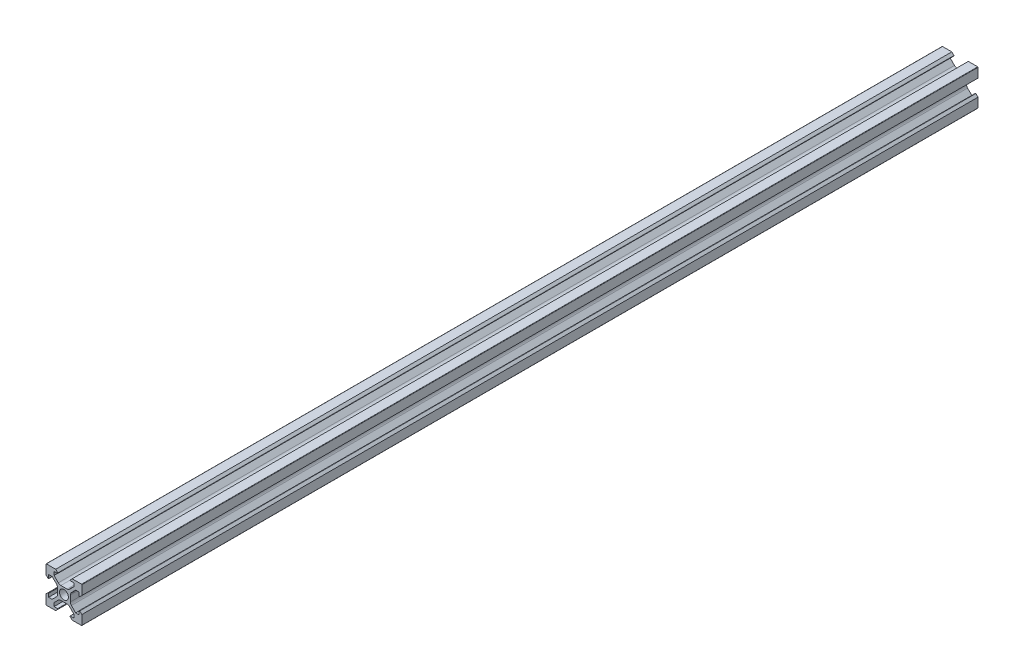
from build123d import *

# Parameters (mm, degrees)
ESBO_O1_R                = 2.5
RESSALTO_EXTRUS_O1_DEPTH = 500


with BuildPart() as part:
    # Esboço1 → Ressalto-extrusão1 (new body)
    with BuildSketch(Plane.XY):
        with BuildLine():
            Line((-4.6, -10), (-9.8, -10))
            ThreePointArc((-9.8, -10), (-9.941421356, -9.941421356), (-10, -9.8))
            Line((-10, -9.8), (-10, -4.6))
            Line((-10, -4.6), (-8.841421356, -3.441421356))
            ThreePointArc((-8.841421356, -3.441421356), (-8.623463314, -3.398066806), (-8.5, -3.582842712))
            Line((-8.5, -3.582842712), (-8.5, -5.5))
            Line((-8.5, -5.5), (-6.560660172, -5.5))
            Line((-6.560660172, -5.5), (-4.185786438, -3.125126266))
            ThreePointArc((-4.185786438, -3.125126266), (-3.752240935, -2.476279568), (-3.6, -1.710912703))
            Line((-3.6, -1.710912703), (-3.6, 1.710912703))
            ThreePointArc((-3.6, 1.710912703), (-3.752240935, 2.476279568), (-4.185786438, 3.125126266))
            Line((-4.185786438, 3.125126266), (-6.560660172, 5.5))
            Line((-6.560660172, 5.5), (-8.5, 5.5))
            Line((-8.5, 5.5), (-8.5, 3.582842712))
            ThreePointArc((-8.5, 3.582842712), (-8.623463314, 3.398066806), (-8.841421356, 3.441421356))
            Line((-8.841421356, 3.441421356), (-10, 4.6))
            Line((-10, 4.6), (-10, 9.8))
            ThreePointArc((-10, 9.8), (-9.941421356, 9.941421356), (-9.8, 10))
            Line((-9.8, 10), (-4.6, 10))
            Line((-4.6, 10), (-3.441421356, 8.841421356))
            ThreePointArc((-3.441421356, 8.841421356), (-3.398066806, 8.623463314), (-3.582842712, 8.5))
            Line((-3.582842712, 8.5), (-5.5, 8.5))
            Line((-5.5, 8.5), (-5.5, 6.560660172))
            Line((-5.5, 6.560660172), (-3.125126266, 4.185786438))
            ThreePointArc((-3.125126266, 4.185786438), (-2.476279568, 3.752240935), (-1.710912703, 3.6))
            Line((-1.710912703, 3.6), (1.710912703, 3.6))
            ThreePointArc((1.710912703, 3.6), (2.476279568, 3.752240935), (3.125126266, 4.185786438))
            Line((3.125126266, 4.185786438), (5.5, 6.560660172))
            Line((5.5, 6.560660172), (5.5, 8.5))
            Line((5.5, 8.5), (3.582842712, 8.5))
            ThreePointArc((3.582842712, 8.5), (3.398066806, 8.623463314), (3.441421356, 8.841421356))
            Line((3.441421356, 8.841421356), (4.6, 10))
            Line((4.6, 10), (9.8, 10))
            ThreePointArc((9.8, 10), (9.941421356, 9.941421356), (10, 9.8))
            Line((10, 9.8), (10, 4.6))
            Line((10, 4.6), (8.841421356, 3.441421356))
            ThreePointArc((8.841421356, 3.441421356), (8.623463314, 3.398066806), (8.5, 3.582842712))
            Line((8.5, 3.582842712), (8.5, 5.5))
            Line((8.5, 5.5), (6.560660172, 5.5))
            Line((6.560660172, 5.5), (4.185786438, 3.125126266))
            ThreePointArc((4.185786438, 3.125126266), (3.752240935, 2.476279568), (3.6, 1.710912703))
            Line((3.6, 1.710912703), (3.6, -1.710912703))
            ThreePointArc((3.6, -1.710912703), (3.752240935, -2.476279568), (4.185786438, -3.125126266))
            Line((4.185786438, -3.125126266), (6.560660172, -5.5))
            Line((6.560660172, -5.5), (8.5, -5.5))
            Line((8.5, -5.5), (8.5, -3.582842712))
            ThreePointArc((8.5, -3.582842712), (8.623463314, -3.398066806), (8.841421356, -3.441421356))
            Line((8.841421356, -3.441421356), (10, -4.6))
            Line((10, -4.6), (10, -9.8))
            ThreePointArc((10, -9.8), (9.941421356, -9.941421356), (9.8, -10))
            Line((9.8, -10), (4.6, -10))
            Line((4.6, -10), (3.441421356, -8.841421356))
            ThreePointArc((3.441421356, -8.841421356), (3.398066806, -8.623463314), (3.582842712, -8.5))
            Line((3.582842712, -8.5), (5.5, -8.5))
            Line((5.5, -8.5), (5.5, -6.560660172))
            Line((5.5, -6.560660172), (3.125126266, -4.185786438))
            ThreePointArc((3.125126266, -4.185786438), (2.476279568, -3.752240935), (1.710912703, -3.6))
            Line((1.710912703, -3.6), (-1.710912703, -3.6))
            ThreePointArc((-1.710912703, -3.6), (-2.476279568, -3.752240935), (-3.125126266, -4.185786438))
            Line((-3.125126266, -4.185786438), (-5.5, -6.560660172))
            Line((-5.5, -6.560660172), (-5.5, -8.5))
            Line((-5.5, -8.5), (-3.582842712, -8.5))
            ThreePointArc((-3.582842712, -8.5), (-3.398066806, -8.623463314), (-3.441421356, -8.841421356))
            Line((-3.441421356, -8.841421356), (-4.6, -10))
        make_face()
        Circle(ESBO_O1_R, mode=Mode.SUBTRACT)
    extrude(amount=RESSALTO_EXTRUS_O1_DEPTH)


solid = part.part
